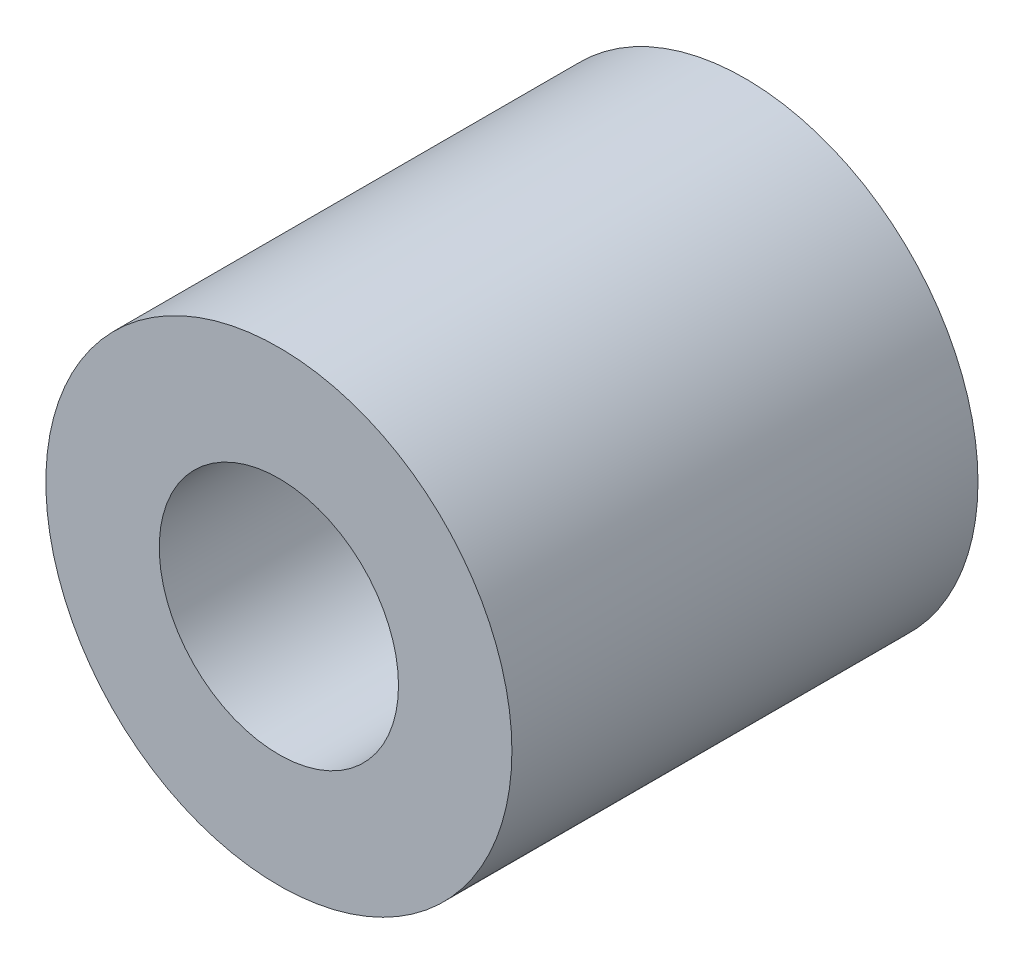
from build123d import *

# Parameters (mm, degrees)
ESQUISSE1_R      = 3
ESQUISSE1_R_2    = 1.54
EXTRUSION1_DEPTH = 6


with BuildPart() as part:
    # Esquisse1 → Extrusion1 (new body)
    with BuildSketch(Plane.XY):
        Circle(ESQUISSE1_R)
        Circle(ESQUISSE1_R_2, mode=Mode.SUBTRACT)
    extrude(amount=EXTRUSION1_DEPTH)


solid = part.part
